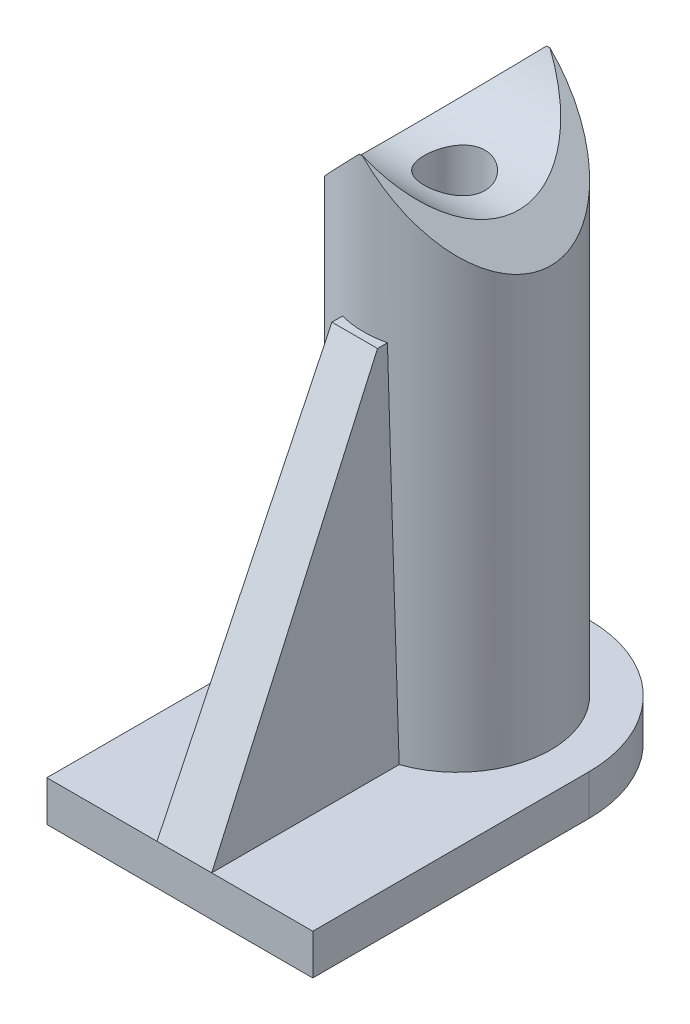
from build123d import *

# Parameters (mm, degrees)
SKETCH1_W           = 10.5
SKETCH1_H           = 16.1
BOSS_EXTRUDE1_DEPTH = 1.6
FILLET1_R           = 5.2
SKETCH2_R           = 3.7
BOSS_EXTRUDE2_DEPTH = 20.3
SKETCH3_R           = 4.004738107
CUT_EXTRUDE1_DEPTH  = 20.3
CUT_EXTRUDE2_START  = 14.8
CUT_EXTRUDE2_DEPTH  = 6.500000101
CUT_EXTRUDE4_DEPTH  = 20.3
SKETCH6_R           = 2.275
CUT_EXTRUDE5_DEPTH  = 16.3
CHAMFER1_SIZE       = 1
CUT_EXTRUDE6_REACH  = 7.599
SKETCH7_R           = 1.2
BOSS_EXTRUDE4_REACH = 18.1
CUT_EXTRUDE8_REACH  = 8.15


with BuildPart() as part:
    # Sketch1 → Boss-Extrude1 (new body)
    with BuildSketch(Plane(origin=(0, 0, 0), x_dir=(1, 0, 0), z_dir=(0, 1, 0))):
        with Locations((5.25, -8.05)):
            Rectangle(SKETCH1_W, SKETCH1_H)
    extrude(amount=BOSS_EXTRUDE1_DEPTH)

    # Fillet1
    fillet1_edges = [part.edges().sort_by_distance(p)[0] for p in [
        (0, 0.8, 0),
        (10.5, 0.8, 0),
    ]]
    fillet(fillet1_edges, radius=FILLET1_R)

    # Sketch2 → Boss-Extrude2 (add)
    with BuildSketch(Plane(origin=(0, 1.6, 0), x_dir=(1, 0, 0), z_dir=(0, 1, 0))):
        with Locations((5.2, -5.2)):
            Circle(SKETCH2_R)
    extrude(amount=BOSS_EXTRUDE2_DEPTH)

    # Sketch3 → Cut-Extrude1 (cut)
    with BuildSketch(Plane(origin=(10.5, 0, 0), x_dir=(0, 0, -1), z_dir=(1, 0, 0))):
        with Locations((-5.2, 23.432294784)):
            Circle(SKETCH3_R)
    extrude(amount=-CUT_EXTRUDE1_DEPTH, mode=Mode.SUBTRACT)

    # Sketch4 → Cut-Extrude2 (cut, through all)
    with BuildSketch(Plane(origin=(0, 1.6, 0), x_dir=(1, 0, 0), z_dir=(0, 1, 0)).offset(CUT_EXTRUDE2_START)):
        with BuildLine():
            Line((7.790601515, -2.558261218), (7.790601515, -7.841738782))
            ThreePointArc((7.790601515, -7.841738782), (8.9, -5.2), (7.790601515, -2.558261218))
        make_face()
    extrude(amount=CUT_EXTRUDE2_DEPTH, mode=Mode.SUBTRACT)

    # Sketch5 → Cut-Extrude4 (cut)
    with BuildSketch(Plane.XY.offset(16.1)):
        Polygon((5.3, 21.958982239), (7.790601515, 19.4), (9.828300682, 21.383248088), (4.534562835, 26.822328186), (-0.186346152, 21.958982239), (1.5, 18.158982239), align=None)
    extrude(amount=-CUT_EXTRUDE4_DEPTH, mode=Mode.SUBTRACT)

    # Sketch6 → Cut-Extrude5 (cut)
    with BuildSketch(Plane(origin=(0, 0, 0), x_dir=(-1, 0, 0), z_dir=(0, -1, 0))):
        with Locations((-5.3, -5.2)):
            Circle(SKETCH6_R)
    extrude(amount=-CUT_EXTRUDE5_DEPTH, mode=Mode.SUBTRACT)

    # Chamfer1
    chamfer1_edges = [part.edges().sort_by_distance(p)[0] for p in [
        (7.575, 0, 5.2),
    ]]
    chamfer(chamfer1_edges, length=CHAMFER1_SIZE)

    # Sketch7 → Cut-Extrude6 (cut, up to next)
    with BuildSketch(Plane.XZ.offset(-16.3), mode=Mode.PRIVATE) as cut_extrude6_sk1:
        with Locations((5.3, 5.2)):
            Circle(SKETCH7_R)
    cut_extrude6_tool1 = extrude(cut_extrude6_sk1.sketch, amount=-CUT_EXTRUDE6_REACH, mode=Mode.PRIVATE) & part.part
    add(cut_extrude6_tool1.solids().sort_by_distance((5.3, 16.3, 5.2))[0], mode=Mode.SUBTRACT)

    # Sketch8 → Boss-Extrude4 (add, up to next)
    with BuildSketch(Plane.XY.offset(16.1), mode=Mode.PRIVATE) as boss_extrude4_sk1:
        Polygon((4.35, 15.9), (3.991182401, 1.6), (6.15, 1.6), (6.15, 15.9), align=None)
    boss_extrude4_tool1 = extrude(boss_extrude4_sk1.sketch, amount=-BOSS_EXTRUDE4_REACH, mode=Mode.PRIVATE) - part.part
    add(boss_extrude4_tool1.solids().sort_by_distance((5.157585, 8.53398, 16.1))[0])

    # Sketch11 → Cut-Extrude8 (cut, up to next)
    with BuildSketch(Plane(origin=(6.15, 0, 0), x_dir=(0, 0, -1), z_dir=(1, 0, 0)), mode=Mode.PRIVATE) as cut_extrude8_sk1:
        Polygon((-16.1, 15.9), (-16.1, 1.6), (-9.19348511, 15.9), align=None)
    cut_extrude8_tool1 = extrude(cut_extrude8_sk1.sketch, amount=-CUT_EXTRUDE8_REACH, mode=Mode.PRIVATE) & part.part
    add(cut_extrude8_tool1.solids().sort_by_distance((6.15, 11.133333, 13.797828))[0], mode=Mode.SUBTRACT)


with BuildPart() as body_2:
    # Mirror3: mirrored copy
    add(part.part.mirror(Plane(origin=(0, 1.6, 0), x_dir=(0, 0, 1), z_dir=(1, 0, 0))))


solid = body_2.part
